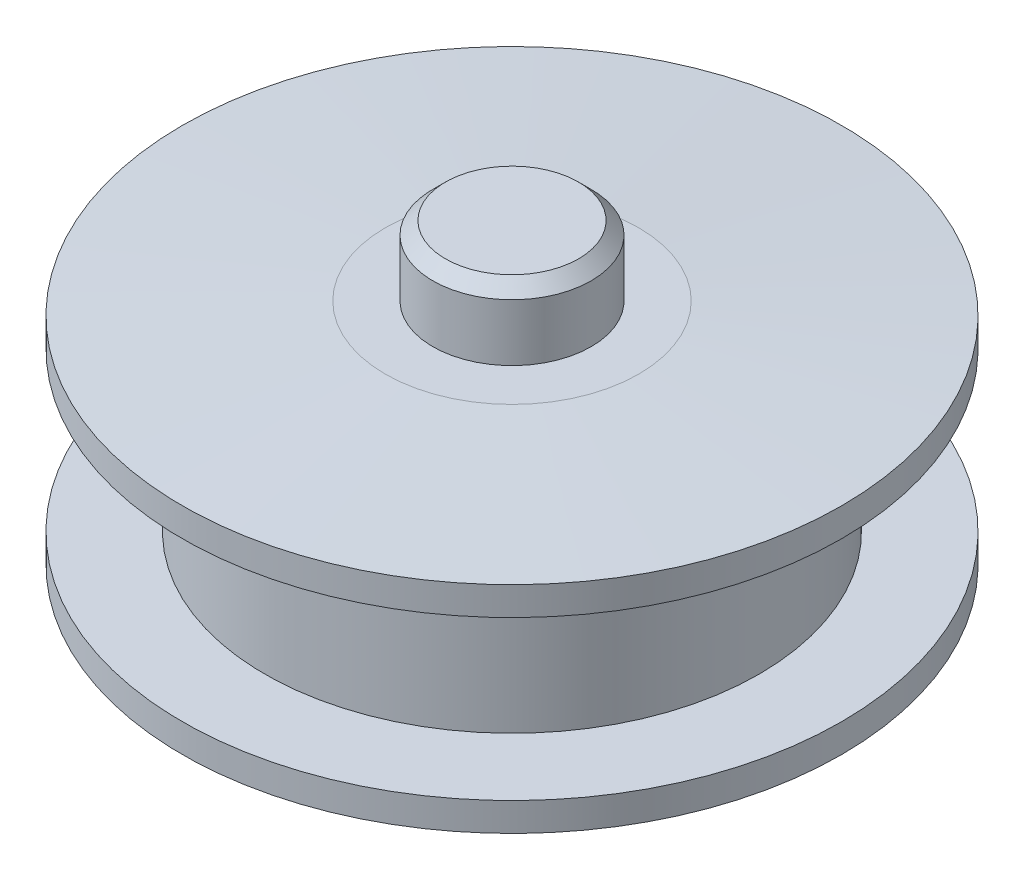
from build123d import *


with BuildPart() as part:
    # Sketch1 → Revolve1 (revolve)
    with BuildSketch(Plane.XY):
        Polygon((1.05, 3), (0, 3), (0, -3), (1.05, -3), (1.25, -2.8), (1.25, -1.9), (2, -1.9), (5.2, -1.7), (5.2, -1.25), (3.9, -1.25), (3.9, 1.25), (5.2, 1.25), (5.2, 1.7), (2, 1.9), (1.25, 1.9), (1.25, 2.8), align=None)
    revolve(axis=Axis((0, 3, 0), (0, -1, 0)))


solid = part.part
